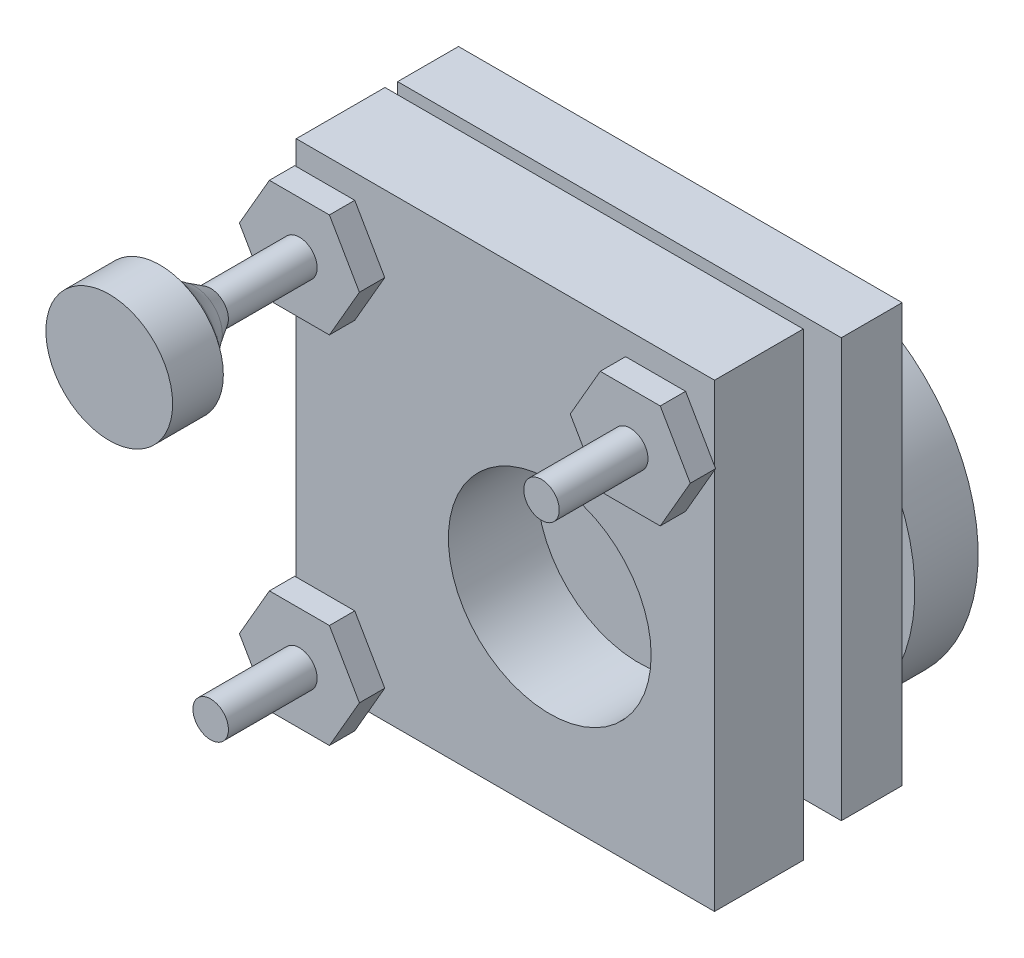
from build123d import *

# Parameters (mm, degrees)
CROQUIS1_W              = 33
CROQUIS1_H              = 7
SALIENTE_EXTRUIR1_DEPTH = 36.3
CROQUIS2_R              = 1.5
CORTAR_EXTRUIR1_DEPTH   = 5
CROQUIS3_R              = 8
CORTAR_EXTRUIR2_DEPTH   = 8
CROQUIS4_R              = 2.4
SALIENTE_EXTRUIR2_DEPTH = 1.2
SALIENTE_EXTRUIR3_DEPTH = 2
CROQUIS6_R              = 1.4
SALIENTE_EXTRUIR4_DEPTH = 7
CROQUIS9_W              = 35
CROQUIS9_H              = 33
SALIENTE_EXTRUIR5_DEPTH = 4.8
CROQUIS10_R             = 5.839659477
SALIENTE_EXTRUIR6_DEPTH = 1
CROQUIS11_R             = 14
SALIENTE_EXTRUIR7_DEPTH = 5
CROQUIS12_R             = 8
CORTAR_EXTRUIR3_DEPTH   = 1


with BuildPart() as part:
    # Croquis1 → Saliente-Extruir1 (new body)
    with BuildSketch(Plane(origin=(0, 0, 0), x_dir=(1, 0, 0), z_dir=(0, 1, 0))):
        Rectangle(CROQUIS1_W, CROQUIS1_H)
    extrude(amount=SALIENTE_EXTRUIR1_DEPTH)

    # Croquis2 → Cortar-Extruir1 (cut)
    with BuildSketch(Plane.XZ):
        with Locations((-6.8, 0)):
            Circle(CROQUIS2_R)
        with Locations((9.3, 0)):
            Circle(CROQUIS2_R)
    extrude(amount=-CORTAR_EXTRUIR1_DEPTH, mode=Mode.SUBTRACT)

    # Croquis3 → Cortar-Extruir2 (cut, through all)
    with BuildSketch(Plane.XY.offset(3.5)):
        with Locations((3.5, 15)):
            Circle(CROQUIS3_R)
    extrude(amount=-CORTAR_EXTRUIR2_DEPTH, mode=Mode.SUBTRACT)

    # Croquis4 → Saliente-Extruir2 (add)
    with BuildSketch(Plane.XY.offset(3.5)):
        with Locations((-13.05, 31.5)):
            Circle(CROQUIS4_R)
        with Locations((13.05, 31.5)):
            Circle(CROQUIS4_R)
        with Locations((-13.05, 3.45)):
            Circle(CROQUIS4_R)
    extrude(amount=SALIENTE_EXTRUIR2_DEPTH)

    # Croquis5 → Saliente-Extruir3 (add)
    with BuildSketch(Plane.XY.offset(4.7)):
        Polygon((-17.784272207, 31.5), (-15.417136104, 27.4), (-10.682863896, 27.4), (-8.315727793, 31.5), (-10.682863896, 35.6), (-15.417136104, 35.6), align=None)
        Polygon((17.784272207, 31.5), (15.417136104, 35.6), (10.682863896, 35.6), (8.315727793, 31.5), (10.682863896, 27.4), (15.417136104, 27.4), align=None)
        Polygon((-8.315727793, 3.45), (-10.682863896, 7.55), (-15.417136104, 7.55), (-17.784272207, 3.45), (-15.417136104, -0.65), (-10.682863896, -0.65), align=None)
    extrude(amount=SALIENTE_EXTRUIR3_DEPTH)

    # Croquis6 → Saliente-Extruir4 (add)
    with BuildSketch(Plane.XY.offset(6.7)):
        with Locations((-13.05, 31.5)):
            Circle(CROQUIS6_R)
        with Locations((13.05, 31.5)):
            Circle(CROQUIS6_R)
        with Locations((-13.05, 3.45)):
            Circle(CROQUIS6_R)
    extrude(amount=SALIENTE_EXTRUIR4_DEPTH)

    # Croquis8 → Revolución1 (revolve)
    with BuildSketch(Plane.XZ.offset(-31.5)):
        with BuildLine():
            Line((-14.45, 13.7), (-15.232399286, 14.962983287))
            ThreePointArc((-15.232399286, 14.962983287), (-15.987008603, 15.967113671), (-16.908922521, 16.820218458))
            Line((-16.908922521, 16.820218458), (-18.05, 17.7))
            Line((-18.05, 17.7), (-18.05, 21.7))
            Line((-18.05, 21.7), (-13.05, 21.7))
            Line((-13.05, 21.7), (-13.05, 13.7))
            Line((-13.05, 13.7), (-14.45, 13.7))
        make_face()
    revolve(axis=Axis((-13.05, 31.5, 21.7), (0, 0, -1)))


with BuildPart() as body_2:
    # Croquis9 → Saliente-Extruir5 (new body)
    with BuildSketch(Plane(origin=(0, 0, -5.5), x_dir=(-1, 0, 0), z_dir=(0, 0, -1))):
        with Locations((0, 18.7)):
            Rectangle(CROQUIS9_W, CROQUIS9_H)
    extrude(amount=SALIENTE_EXTRUIR5_DEPTH)

    # Croquis10 → Saliente-Extruir6 (add)
    with BuildSketch(Plane(origin=(0, 0, -10.3), x_dir=(-1, 0, 0), z_dir=(0, 0, -1))):
        with Locations((-3.5, 15)):
            Circle(CROQUIS10_R)
    extrude(amount=SALIENTE_EXTRUIR6_DEPTH)

    # Croquis11 → Saliente-Extruir7 (add)
    with BuildSketch(Plane(origin=(0, 0, -11.3), x_dir=(-1, 0, 0), z_dir=(0, 0, -1))):
        with Locations((-3.5, 15)):
            Circle(CROQUIS11_R)
    extrude(amount=SALIENTE_EXTRUIR7_DEPTH)

    # Croquis12 → Cortar-Extruir3 (cut)
    with BuildSketch(Plane(origin=(0, 0, -16.3), x_dir=(-1, 0, 0), z_dir=(0, 0, -1))):
        with Locations((-3.5, 15)):
            Circle(CROQUIS12_R)
    extrude(amount=-CORTAR_EXTRUIR3_DEPTH, mode=Mode.SUBTRACT)


solid = Compound([part.part, body_2.part])
